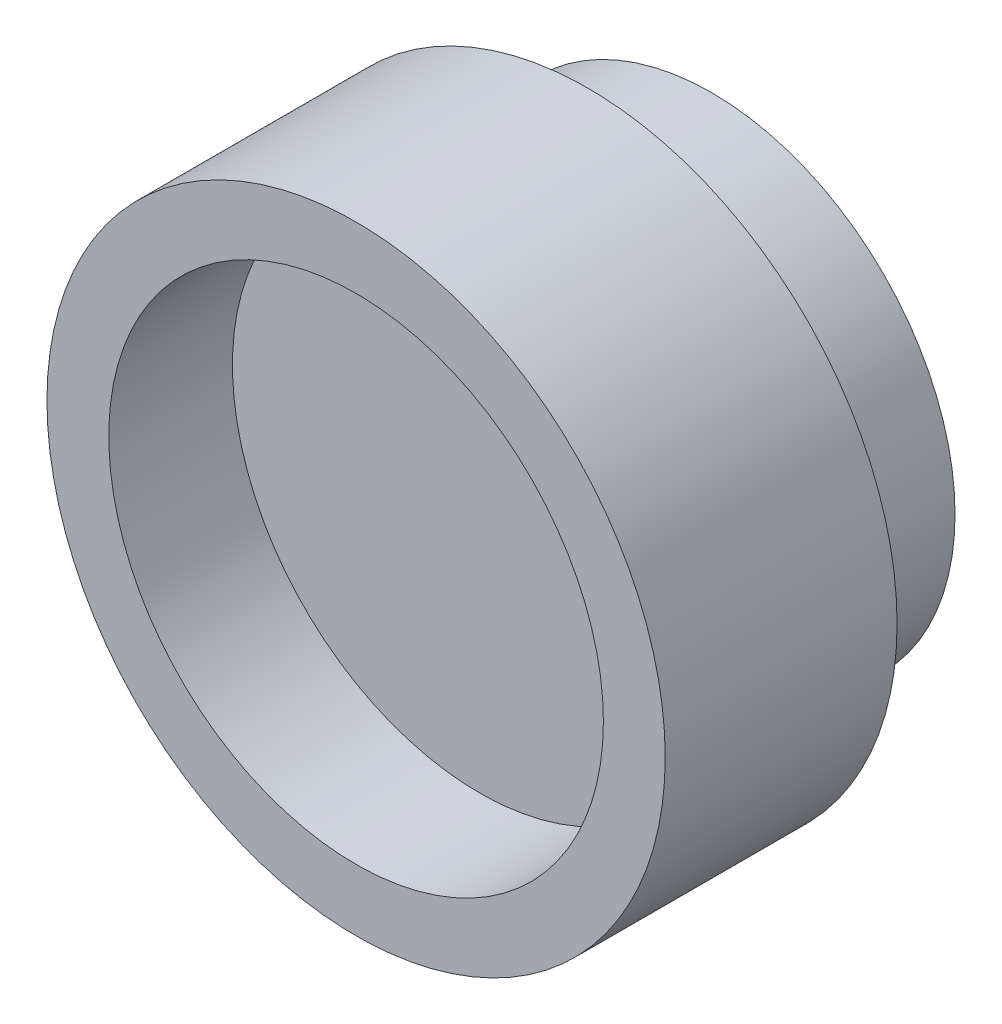
from build123d import *

# Parameters (mm, degrees)
SKETCH1_R           = 15.75
BOSS_EXTRUDE1_DEPTH = 23
SKETCH2_R           = 20
BOSS_EXTRUDE2_DEPTH = 15
SKETCH3_R           = 16
CUT_EXTRUDE1_DEPTH  = 8


with BuildPart() as part:
    # Sketch1 → Boss-Extrude1 (new body)
    with BuildSketch(Plane.XY):
        Circle(SKETCH1_R)
    extrude(amount=BOSS_EXTRUDE1_DEPTH)

    # Sketch2 → Boss-Extrude2 (add)
    with BuildSketch(Plane.XY.offset(23)):
        Circle(SKETCH2_R)
    extrude(amount=-BOSS_EXTRUDE2_DEPTH)

    # Sketch3 → Cut-Extrude1 (cut)
    with BuildSketch(Plane.XY.offset(23)):
        Circle(SKETCH3_R)
    extrude(amount=-CUT_EXTRUDE1_DEPTH, mode=Mode.SUBTRACT)


solid = part.part
